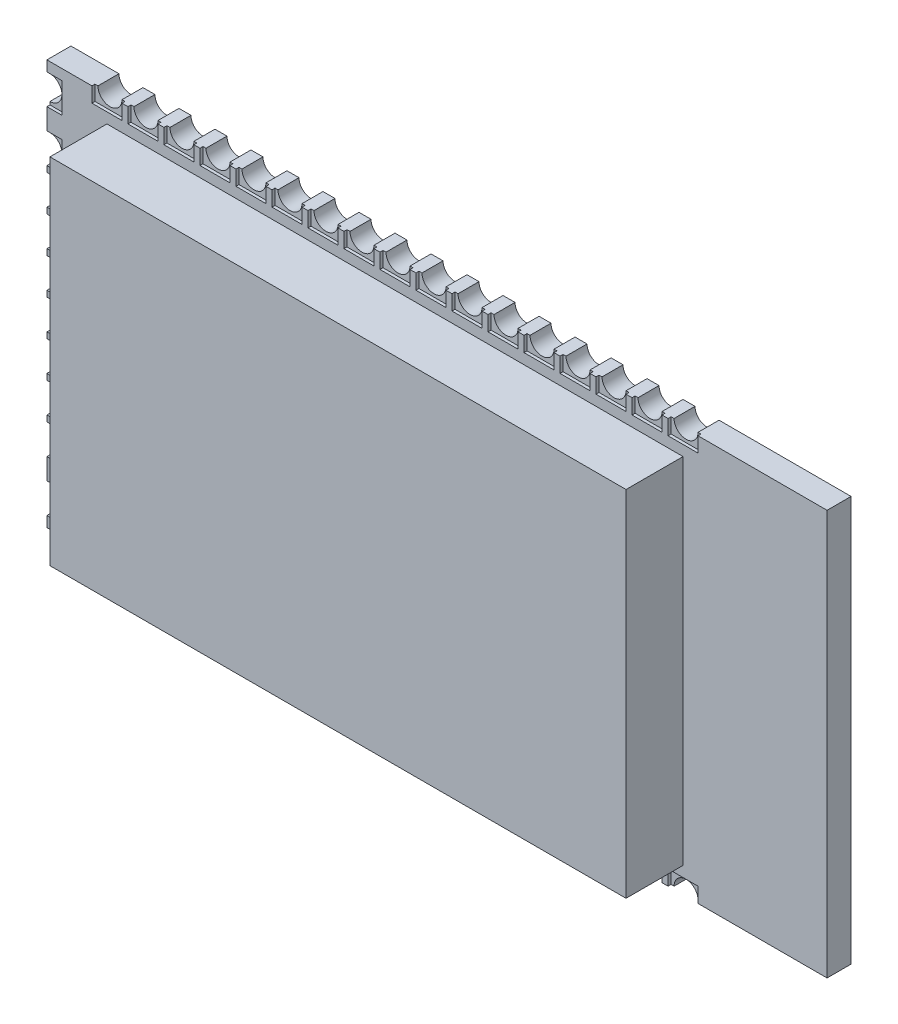
from build123d import *

# Parameters (mm, degrees)
SKETCH1_W                = 26
SKETCH1_H                = 13.5
BOSS_EXTRUDE1_DEPTH      = 0.8
SKETCH2_W                = 19.2
SKETCH2_H                = 11.8
BOSS_EXTRUDE2_DEPTH      = 1.9
CUT_EXTRUDE1_DEPTH       = 0.8
SKETCH4_W                = 1
SKETCH4_H                = 0.5
CUT_EXTRUDE2_DEPTH       = 0.1
CUT_EXTRUDE3_DEPTH       = 0.8
SKETCH6_W                = 0.5
SKETCH6_H                = 1
CUT_EXTRUDE4_DEPTH       = 0.1
LPATTERN1_COUNT          = 17
LPATTERN1_PITCH          = 1.2
MIRROR1_COPY_1_DEPTH     = 0.8
MIRROR1_COPY_2_DEPTH     = 0.8
MIRROR1_COPY_3_DEPTH     = 0.8
MIRROR1_COPY_4_DEPTH     = 0.8
MIRROR1_COPY_5_DEPTH     = 0.8
MIRROR1_COPY_6_DEPTH     = 0.8
MIRROR1_COPY_7_DEPTH     = 0.8
MIRROR1_COPY_8_DEPTH     = 0.8
MIRROR1_COPY_9_DEPTH     = 0.8
MIRROR1_COPY_10_DEPTH    = 0.8
MIRROR1_COPY_11_DEPTH    = 0.8
MIRROR1_COPY_12_DEPTH    = 0.8
MIRROR1_COPY_13_DEPTH    = 0.8
MIRROR1_COPY_14_DEPTH    = 0.8
MIRROR1_COPY_15_DEPTH    = 0.8
MIRROR1_COPY_16_DEPTH    = 0.8
MIRROR1_COPY_17_SKETCH_W = 1
MIRROR1_COPY_17_SKETCH_H = 0.5
MIRROR1_COPY_17_DEPTH    = 0.1
MIRROR1_COPY_18_SKETCH_W = 1
MIRROR1_COPY_18_SKETCH_H = 0.5
MIRROR1_COPY_18_DEPTH    = 0.1
MIRROR1_COPY_19_SKETCH_W = 1
MIRROR1_COPY_19_SKETCH_H = 0.5
MIRROR1_COPY_19_DEPTH    = 0.1
MIRROR1_COPY_20_SKETCH_W = 1
MIRROR1_COPY_20_SKETCH_H = 0.5
MIRROR1_COPY_20_DEPTH    = 0.1
MIRROR1_COPY_21_SKETCH_W = 1
MIRROR1_COPY_21_SKETCH_H = 0.5
MIRROR1_COPY_21_DEPTH    = 0.1
MIRROR1_COPY_22_SKETCH_W = 1
MIRROR1_COPY_22_SKETCH_H = 0.5
MIRROR1_COPY_22_DEPTH    = 0.1
MIRROR1_COPY_23_SKETCH_W = 1
MIRROR1_COPY_23_SKETCH_H = 0.5
MIRROR1_COPY_23_DEPTH    = 0.1
MIRROR1_COPY_24_SKETCH_W = 1
MIRROR1_COPY_24_SKETCH_H = 0.5
MIRROR1_COPY_24_DEPTH    = 0.1
MIRROR1_COPY_25_SKETCH_W = 1
MIRROR1_COPY_25_SKETCH_H = 0.5
MIRROR1_COPY_25_DEPTH    = 0.1
MIRROR1_COPY_26_SKETCH_W = 1
MIRROR1_COPY_26_SKETCH_H = 0.5
MIRROR1_COPY_26_DEPTH    = 0.1
MIRROR1_COPY_27_SKETCH_W = 1
MIRROR1_COPY_27_SKETCH_H = 0.5
MIRROR1_COPY_27_DEPTH    = 0.1
MIRROR1_COPY_28_SKETCH_W = 1
MIRROR1_COPY_28_SKETCH_H = 0.5
MIRROR1_COPY_28_DEPTH    = 0.1
MIRROR1_COPY_29_SKETCH_W = 1
MIRROR1_COPY_29_SKETCH_H = 0.5
MIRROR1_COPY_29_DEPTH    = 0.1
MIRROR1_COPY_30_SKETCH_W = 1
MIRROR1_COPY_30_SKETCH_H = 0.5
MIRROR1_COPY_30_DEPTH    = 0.1
MIRROR1_COPY_31_SKETCH_W = 1
MIRROR1_COPY_31_SKETCH_H = 0.5
MIRROR1_COPY_31_DEPTH    = 0.1
MIRROR1_COPY_32_SKETCH_W = 1
MIRROR1_COPY_32_SKETCH_H = 0.5
MIRROR1_COPY_32_DEPTH    = 0.1
CUT_EXTRUDE5_DEPTH       = 0.8
SKETCH8_W                = 0.5
SKETCH8_H                = 1
CUT_EXTRUDE6_DEPTH       = 0.1
LPATTERN3_COUNT          = 8
LPATTERN3_PITCH          = 1.2


with BuildPart() as part:
    # Sketch1 → Boss-Extrude1 (new body)
    with BuildSketch(Plane.XY):
        with Locations((13, 6.75)):
            Rectangle(SKETCH1_W, SKETCH1_H)
    extrude(amount=BOSS_EXTRUDE1_DEPTH)

    # Sketch2 → Boss-Extrude2 (add)
    with BuildSketch(Plane.XY.offset(0.8)):
        with Locations((11.6, 6.75)):
            Rectangle(SKETCH2_W, SKETCH2_H)
    extrude(amount=BOSS_EXTRUDE2_DEPTH)

    # Sketch3 → Cut-Extrude1 (cut)
    with BuildSketch(Plane.XY.offset(0.8)):
        with BuildLine():
            Line((1.6, 13.5), (2.4, 13.5))
            ThreePointArc((2.4, 13.5), (2, 13.1), (1.6, 13.5))
        make_face()
    cut_extrude1 = extrude(amount=-CUT_EXTRUDE1_DEPTH, mode=Mode.SUBTRACT)

    # Sketch4 → Cut-Extrude2 (cut)
    with BuildSketch(Plane.XY.offset(0.8)):
        with Locations((2, 13.25)):
            Rectangle(SKETCH4_W, SKETCH4_H)
    cut_extrude2 = extrude(amount=-CUT_EXTRUDE2_DEPTH, mode=Mode.SUBTRACT)

    # Sketch5 → Cut-Extrude3 (cut)
    with BuildSketch(Plane.XY.offset(0.8)):
        with BuildLine():
            Line((0, 13.05), (0, 12.25))
            ThreePointArc((0, 12.25), (0.4, 12.65), (0, 13.05))
        make_face()
    cut_extrude3 = extrude(amount=-CUT_EXTRUDE3_DEPTH, mode=Mode.SUBTRACT)

    # Sketch6 → Cut-Extrude4 (cut)
    with BuildSketch(Plane.XY.offset(0.8)):
        with Locations((0.25, 12.65)):
            Rectangle(SKETCH6_W, SKETCH6_H)
    cut_extrude4 = extrude(amount=-CUT_EXTRUDE4_DEPTH, mode=Mode.SUBTRACT)

    # LPattern1: Cut-Extrude1, Cut-Extrude2 ×17
    with Locations(*[(i * LPATTERN1_PITCH, 0, 0) for i in range(1, LPATTERN1_COUNT)]):
        add(cut_extrude1, mode=Mode.SUBTRACT)
        add(cut_extrude2, mode=Mode.SUBTRACT)

    # Mirror1: Cut-Extrude3, Cut-Extrude4, Cut-Extrude1, Cut-Extrude2 across plane
    add(cut_extrude3.mirror(Plane.ZX.offset(6.75)), mode=Mode.SUBTRACT)
    add(cut_extrude4.mirror(Plane.ZX.offset(6.75)), mode=Mode.SUBTRACT)
    add(cut_extrude1.mirror(Plane.ZX.offset(6.75)), mode=Mode.SUBTRACT)
    add(cut_extrude2.mirror(Plane.ZX.offset(6.75)), mode=Mode.SUBTRACT)

    # Mirror1 copy 1 sketch → Mirror1 copy 1 (cut)
    with BuildSketch(Plane(origin=(1.2, 13.5, 0.8), x_dir=(1, 0, 0), z_dir=(0, 0, 1))):
        with BuildLine():
            Line((1.6, -13.5), (2.4, -13.5))
            ThreePointArc((2.4, -13.5), (2, -13.1), (1.6, -13.5))
        make_face()
    extrude(amount=-MIRROR1_COPY_1_DEPTH, mode=Mode.SUBTRACT)

    # Mirror1 copy 2 sketch → Mirror1 copy 2 (cut)
    with BuildSketch(Plane(origin=(2.4, 13.5, 0.8), x_dir=(1, 0, 0), z_dir=(0, 0, 1))):
        with BuildLine():
            Line((1.6, -13.5), (2.4, -13.5))
            ThreePointArc((2.4, -13.5), (2, -13.1), (1.6, -13.5))
        make_face()
    extrude(amount=-MIRROR1_COPY_2_DEPTH, mode=Mode.SUBTRACT)

    # Mirror1 copy 3 sketch → Mirror1 copy 3 (cut)
    with BuildSketch(Plane(origin=(3.6, 13.5, 0.8), x_dir=(1, 0, 0), z_dir=(0, 0, 1))):
        with BuildLine():
            Line((1.6, -13.5), (2.4, -13.5))
            ThreePointArc((2.4, -13.5), (2, -13.1), (1.6, -13.5))
        make_face()
    extrude(amount=-MIRROR1_COPY_3_DEPTH, mode=Mode.SUBTRACT)

    # Mirror1 copy 4 sketch → Mirror1 copy 4 (cut)
    with BuildSketch(Plane(origin=(4.8, 13.5, 0.8), x_dir=(1, 0, 0), z_dir=(0, 0, 1))):
        with BuildLine():
            Line((1.6, -13.5), (2.4, -13.5))
            ThreePointArc((2.4, -13.5), (2, -13.1), (1.6, -13.5))
        make_face()
    extrude(amount=-MIRROR1_COPY_4_DEPTH, mode=Mode.SUBTRACT)

    # Mirror1 copy 5 sketch → Mirror1 copy 5 (cut)
    with BuildSketch(Plane(origin=(6, 13.5, 0.8), x_dir=(1, 0, 0), z_dir=(0, 0, 1))):
        with BuildLine():
            Line((1.6, -13.5), (2.4, -13.5))
            ThreePointArc((2.4, -13.5), (2, -13.1), (1.6, -13.5))
        make_face()
    extrude(amount=-MIRROR1_COPY_5_DEPTH, mode=Mode.SUBTRACT)

    # Mirror1 copy 6 sketch → Mirror1 copy 6 (cut)
    with BuildSketch(Plane(origin=(7.2, 13.5, 0.8), x_dir=(1, 0, 0), z_dir=(0, 0, 1))):
        with BuildLine():
            Line((1.6, -13.5), (2.4, -13.5))
            ThreePointArc((2.4, -13.5), (2, -13.1), (1.6, -13.5))
        make_face()
    extrude(amount=-MIRROR1_COPY_6_DEPTH, mode=Mode.SUBTRACT)

    # Mirror1 copy 7 sketch → Mirror1 copy 7 (cut)
    with BuildSketch(Plane(origin=(8.4, 13.5, 0.8), x_dir=(1, 0, 0), z_dir=(0, 0, 1))):
        with BuildLine():
            Line((1.6, -13.5), (2.4, -13.5))
            ThreePointArc((2.4, -13.5), (2, -13.1), (1.6, -13.5))
        make_face()
    extrude(amount=-MIRROR1_COPY_7_DEPTH, mode=Mode.SUBTRACT)

    # Mirror1 copy 8 sketch → Mirror1 copy 8 (cut)
    with BuildSketch(Plane(origin=(9.6, 13.5, 0.8), x_dir=(1, 0, 0), z_dir=(0, 0, 1))):
        with BuildLine():
            Line((1.6, -13.5), (2.4, -13.5))
            ThreePointArc((2.4, -13.5), (2, -13.1), (1.6, -13.5))
        make_face()
    extrude(amount=-MIRROR1_COPY_8_DEPTH, mode=Mode.SUBTRACT)

    # Mirror1 copy 9 sketch → Mirror1 copy 9 (cut)
    with BuildSketch(Plane(origin=(10.8, 13.5, 0.8), x_dir=(1, 0, 0), z_dir=(0, 0, 1))):
        with BuildLine():
            Line((1.6, -13.5), (2.4, -13.5))
            ThreePointArc((2.4, -13.5), (2, -13.1), (1.6, -13.5))
        make_face()
    extrude(amount=-MIRROR1_COPY_9_DEPTH, mode=Mode.SUBTRACT)

    # Mirror1 copy 10 sketch → Mirror1 copy 10 (cut)
    with BuildSketch(Plane(origin=(12, 13.5, 0.8), x_dir=(1, 0, 0), z_dir=(0, 0, 1))):
        with BuildLine():
            Line((1.6, -13.5), (2.4, -13.5))
            ThreePointArc((2.4, -13.5), (2, -13.1), (1.6, -13.5))
        make_face()
    extrude(amount=-MIRROR1_COPY_10_DEPTH, mode=Mode.SUBTRACT)

    # Mirror1 copy 11 sketch → Mirror1 copy 11 (cut)
    with BuildSketch(Plane(origin=(13.2, 13.5, 0.8), x_dir=(1, 0, 0), z_dir=(0, 0, 1))):
        with BuildLine():
            Line((1.6, -13.5), (2.4, -13.5))
            ThreePointArc((2.4, -13.5), (2, -13.1), (1.6, -13.5))
        make_face()
    extrude(amount=-MIRROR1_COPY_11_DEPTH, mode=Mode.SUBTRACT)

    # Mirror1 copy 12 sketch → Mirror1 copy 12 (cut)
    with BuildSketch(Plane(origin=(14.4, 13.5, 0.8), x_dir=(1, 0, 0), z_dir=(0, 0, 1))):
        with BuildLine():
            Line((1.6, -13.5), (2.4, -13.5))
            ThreePointArc((2.4, -13.5), (2, -13.1), (1.6, -13.5))
        make_face()
    extrude(amount=-MIRROR1_COPY_12_DEPTH, mode=Mode.SUBTRACT)

    # Mirror1 copy 13 sketch → Mirror1 copy 13 (cut)
    with BuildSketch(Plane(origin=(15.6, 13.5, 0.8), x_dir=(1, 0, 0), z_dir=(0, 0, 1))):
        with BuildLine():
            Line((1.6, -13.5), (2.4, -13.5))
            ThreePointArc((2.4, -13.5), (2, -13.1), (1.6, -13.5))
        make_face()
    extrude(amount=-MIRROR1_COPY_13_DEPTH, mode=Mode.SUBTRACT)

    # Mirror1 copy 14 sketch → Mirror1 copy 14 (cut)
    with BuildSketch(Plane(origin=(16.8, 13.5, 0.8), x_dir=(1, 0, 0), z_dir=(0, 0, 1))):
        with BuildLine():
            Line((1.6, -13.5), (2.4, -13.5))
            ThreePointArc((2.4, -13.5), (2, -13.1), (1.6, -13.5))
        make_face()
    extrude(amount=-MIRROR1_COPY_14_DEPTH, mode=Mode.SUBTRACT)

    # Mirror1 copy 15 sketch → Mirror1 copy 15 (cut)
    with BuildSketch(Plane(origin=(18, 13.5, 0.8), x_dir=(1, 0, 0), z_dir=(0, 0, 1))):
        with BuildLine():
            Line((1.6, -13.5), (2.4, -13.5))
            ThreePointArc((2.4, -13.5), (2, -13.1), (1.6, -13.5))
        make_face()
    extrude(amount=-MIRROR1_COPY_15_DEPTH, mode=Mode.SUBTRACT)

    # Mirror1 copy 16 sketch → Mirror1 copy 16 (cut)
    with BuildSketch(Plane(origin=(19.2, 13.5, 0.8), x_dir=(1, 0, 0), z_dir=(0, 0, 1))):
        with BuildLine():
            Line((1.6, -13.5), (2.4, -13.5))
            ThreePointArc((2.4, -13.5), (2, -13.1), (1.6, -13.5))
        make_face()
    extrude(amount=-MIRROR1_COPY_16_DEPTH, mode=Mode.SUBTRACT)

    # Mirror1 copy 17 sketch → Mirror1 copy 17 (cut)
    with BuildSketch(Plane(origin=(1.2, 13.5, 0.8), x_dir=(1, 0, 0), z_dir=(0, 0, 1))):
        with Locations((2, -13.25)):
            Rectangle(MIRROR1_COPY_17_SKETCH_W, MIRROR1_COPY_17_SKETCH_H)
    extrude(amount=-MIRROR1_COPY_17_DEPTH, mode=Mode.SUBTRACT)

    # Mirror1 copy 18 sketch → Mirror1 copy 18 (cut)
    with BuildSketch(Plane(origin=(2.4, 13.5, 0.8), x_dir=(1, 0, 0), z_dir=(0, 0, 1))):
        with Locations((2, -13.25)):
            Rectangle(MIRROR1_COPY_18_SKETCH_W, MIRROR1_COPY_18_SKETCH_H)
    extrude(amount=-MIRROR1_COPY_18_DEPTH, mode=Mode.SUBTRACT)

    # Mirror1 copy 19 sketch → Mirror1 copy 19 (cut)
    with BuildSketch(Plane(origin=(3.6, 13.5, 0.8), x_dir=(1, 0, 0), z_dir=(0, 0, 1))):
        with Locations((2, -13.25)):
            Rectangle(MIRROR1_COPY_19_SKETCH_W, MIRROR1_COPY_19_SKETCH_H)
    extrude(amount=-MIRROR1_COPY_19_DEPTH, mode=Mode.SUBTRACT)

    # Mirror1 copy 20 sketch → Mirror1 copy 20 (cut)
    with BuildSketch(Plane(origin=(4.8, 13.5, 0.8), x_dir=(1, 0, 0), z_dir=(0, 0, 1))):
        with Locations((2, -13.25)):
            Rectangle(MIRROR1_COPY_20_SKETCH_W, MIRROR1_COPY_20_SKETCH_H)
    extrude(amount=-MIRROR1_COPY_20_DEPTH, mode=Mode.SUBTRACT)

    # Mirror1 copy 21 sketch → Mirror1 copy 21 (cut)
    with BuildSketch(Plane(origin=(6, 13.5, 0.8), x_dir=(1, 0, 0), z_dir=(0, 0, 1))):
        with Locations((2, -13.25)):
            Rectangle(MIRROR1_COPY_21_SKETCH_W, MIRROR1_COPY_21_SKETCH_H)
    extrude(amount=-MIRROR1_COPY_21_DEPTH, mode=Mode.SUBTRACT)

    # Mirror1 copy 22 sketch → Mirror1 copy 22 (cut)
    with BuildSketch(Plane(origin=(7.2, 13.5, 0.8), x_dir=(1, 0, 0), z_dir=(0, 0, 1))):
        with Locations((2, -13.25)):
            Rectangle(MIRROR1_COPY_22_SKETCH_W, MIRROR1_COPY_22_SKETCH_H)
    extrude(amount=-MIRROR1_COPY_22_DEPTH, mode=Mode.SUBTRACT)

    # Mirror1 copy 23 sketch → Mirror1 copy 23 (cut)
    with BuildSketch(Plane(origin=(8.4, 13.5, 0.8), x_dir=(1, 0, 0), z_dir=(0, 0, 1))):
        with Locations((2, -13.25)):
            Rectangle(MIRROR1_COPY_23_SKETCH_W, MIRROR1_COPY_23_SKETCH_H)
    extrude(amount=-MIRROR1_COPY_23_DEPTH, mode=Mode.SUBTRACT)

    # Mirror1 copy 24 sketch → Mirror1 copy 24 (cut)
    with BuildSketch(Plane(origin=(9.6, 13.5, 0.8), x_dir=(1, 0, 0), z_dir=(0, 0, 1))):
        with Locations((2, -13.25)):
            Rectangle(MIRROR1_COPY_24_SKETCH_W, MIRROR1_COPY_24_SKETCH_H)
    extrude(amount=-MIRROR1_COPY_24_DEPTH, mode=Mode.SUBTRACT)

    # Mirror1 copy 25 sketch → Mirror1 copy 25 (cut)
    with BuildSketch(Plane(origin=(10.8, 13.5, 0.8), x_dir=(1, 0, 0), z_dir=(0, 0, 1))):
        with Locations((2, -13.25)):
            Rectangle(MIRROR1_COPY_25_SKETCH_W, MIRROR1_COPY_25_SKETCH_H)
    extrude(amount=-MIRROR1_COPY_25_DEPTH, mode=Mode.SUBTRACT)

    # Mirror1 copy 26 sketch → Mirror1 copy 26 (cut)
    with BuildSketch(Plane(origin=(12, 13.5, 0.8), x_dir=(1, 0, 0), z_dir=(0, 0, 1))):
        with Locations((2, -13.25)):
            Rectangle(MIRROR1_COPY_26_SKETCH_W, MIRROR1_COPY_26_SKETCH_H)
    extrude(amount=-MIRROR1_COPY_26_DEPTH, mode=Mode.SUBTRACT)

    # Mirror1 copy 27 sketch → Mirror1 copy 27 (cut)
    with BuildSketch(Plane(origin=(13.2, 13.5, 0.8), x_dir=(1, 0, 0), z_dir=(0, 0, 1))):
        with Locations((2, -13.25)):
            Rectangle(MIRROR1_COPY_27_SKETCH_W, MIRROR1_COPY_27_SKETCH_H)
    extrude(amount=-MIRROR1_COPY_27_DEPTH, mode=Mode.SUBTRACT)

    # Mirror1 copy 28 sketch → Mirror1 copy 28 (cut)
    with BuildSketch(Plane(origin=(14.4, 13.5, 0.8), x_dir=(1, 0, 0), z_dir=(0, 0, 1))):
        with Locations((2, -13.25)):
            Rectangle(MIRROR1_COPY_28_SKETCH_W, MIRROR1_COPY_28_SKETCH_H)
    extrude(amount=-MIRROR1_COPY_28_DEPTH, mode=Mode.SUBTRACT)

    # Mirror1 copy 29 sketch → Mirror1 copy 29 (cut)
    with BuildSketch(Plane(origin=(15.6, 13.5, 0.8), x_dir=(1, 0, 0), z_dir=(0, 0, 1))):
        with Locations((2, -13.25)):
            Rectangle(MIRROR1_COPY_29_SKETCH_W, MIRROR1_COPY_29_SKETCH_H)
    extrude(amount=-MIRROR1_COPY_29_DEPTH, mode=Mode.SUBTRACT)

    # Mirror1 copy 30 sketch → Mirror1 copy 30 (cut)
    with BuildSketch(Plane(origin=(16.8, 13.5, 0.8), x_dir=(1, 0, 0), z_dir=(0, 0, 1))):
        with Locations((2, -13.25)):
            Rectangle(MIRROR1_COPY_30_SKETCH_W, MIRROR1_COPY_30_SKETCH_H)
    extrude(amount=-MIRROR1_COPY_30_DEPTH, mode=Mode.SUBTRACT)

    # Mirror1 copy 31 sketch → Mirror1 copy 31 (cut)
    with BuildSketch(Plane(origin=(18, 13.5, 0.8), x_dir=(1, 0, 0), z_dir=(0, 0, 1))):
        with Locations((2, -13.25)):
            Rectangle(MIRROR1_COPY_31_SKETCH_W, MIRROR1_COPY_31_SKETCH_H)
    extrude(amount=-MIRROR1_COPY_31_DEPTH, mode=Mode.SUBTRACT)

    # Mirror1 copy 32 sketch → Mirror1 copy 32 (cut)
    with BuildSketch(Plane(origin=(19.2, 13.5, 0.8), x_dir=(1, 0, 0), z_dir=(0, 0, 1))):
        with Locations((2, -13.25)):
            Rectangle(MIRROR1_COPY_32_SKETCH_W, MIRROR1_COPY_32_SKETCH_H)
    extrude(amount=-MIRROR1_COPY_32_DEPTH, mode=Mode.SUBTRACT)

    # Sketch7 → Cut-Extrude5 (cut)
    with BuildSketch(Plane.XY.offset(0.8)):
        with BuildLine():
            Line((0, 11.35), (0, 10.55))
            ThreePointArc((0, 10.55), (0.4, 10.95), (0, 11.35))
        make_face()
    cut_extrude5 = extrude(amount=-CUT_EXTRUDE5_DEPTH, mode=Mode.SUBTRACT)

    # Sketch8 → Cut-Extrude6 (cut)
    with BuildSketch(Plane.XY.offset(0.8)):
        with Locations((0.25, 10.95)):
            Rectangle(SKETCH8_W, SKETCH8_H)
    cut_extrude6 = extrude(amount=-CUT_EXTRUDE6_DEPTH, mode=Mode.SUBTRACT)

    # LPattern3: Cut-Extrude5, Cut-Extrude6 ×8
    with Locations(*[(0, -i * LPATTERN3_PITCH, 0) for i in range(1, LPATTERN3_COUNT)]):
        add(cut_extrude5, mode=Mode.SUBTRACT)
        add(cut_extrude6, mode=Mode.SUBTRACT)


solid = part.part
